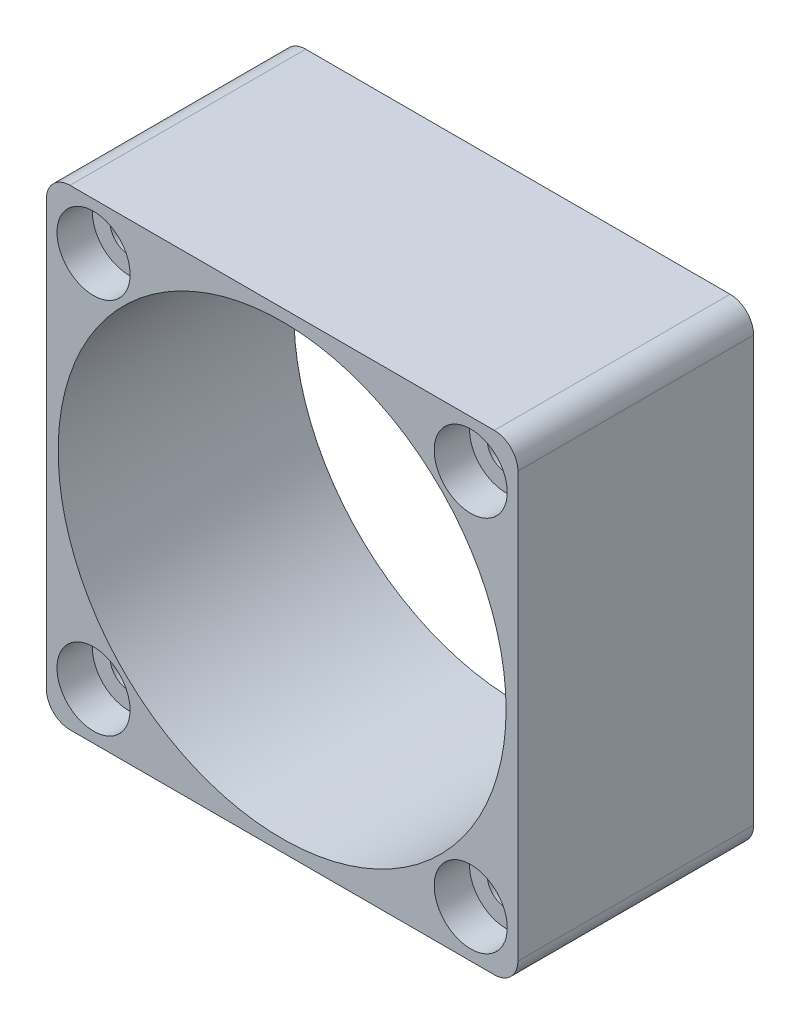
from build123d import *

# Parameters (mm, degrees)
SKETCH1_W           = 40
SKETCH1_H           = 40
BOSS_EXTRUDE1_DEPTH = 20
SKETCH2_R           = 19
SKETCH2_R_2         = 1.6
CUT_EXTRUDE1_DEPTH  = 21
FILLET1_R           = 2
SKETCH3_R           = 3.1
CUT_EXTRUDE2_DEPTH  = 3


with BuildPart() as part:
    # Sketch1 → Boss-Extrude1 (new body)
    with BuildSketch(Plane.XY):
        Rectangle(SKETCH1_W, SKETCH1_H)
    extrude(amount=BOSS_EXTRUDE1_DEPTH)

    # Sketch2 → Cut-Extrude1 (cut, through all)
    with BuildSketch(Plane.XY.offset(20)):
        Circle(SKETCH2_R)
        with Locations((-16, 16)):
            Circle(SKETCH2_R_2)
        with Locations((16, 16)):
            Circle(SKETCH2_R_2)
        with Locations((16, -16)):
            Circle(SKETCH2_R_2)
        with Locations((-16, -16)):
            Circle(SKETCH2_R_2)
    extrude(amount=-CUT_EXTRUDE1_DEPTH, mode=Mode.SUBTRACT)

    # Fillet1
    fillet1_edges = [part.edges().sort_by_distance(p)[0] for p in [
        (20, -20, 10),
        (-20, -20, 10),
        (-20, 20, 10),
        (20, 20, 10),
    ]]
    fillet(fillet1_edges, radius=FILLET1_R)

    # Sketch3 → Cut-Extrude2 (cut)
    with BuildSketch(Plane.XY.offset(20)):
        with Locations((-16, -16)):
            Circle(SKETCH3_R)
        with Locations((16, -16)):
            Circle(SKETCH3_R)
        with Locations((16, 16)):
            Circle(SKETCH3_R)
        with Locations((-16, 16)):
            Circle(SKETCH3_R)
    extrude(amount=-CUT_EXTRUDE2_DEPTH, mode=Mode.SUBTRACT)


solid = part.part
